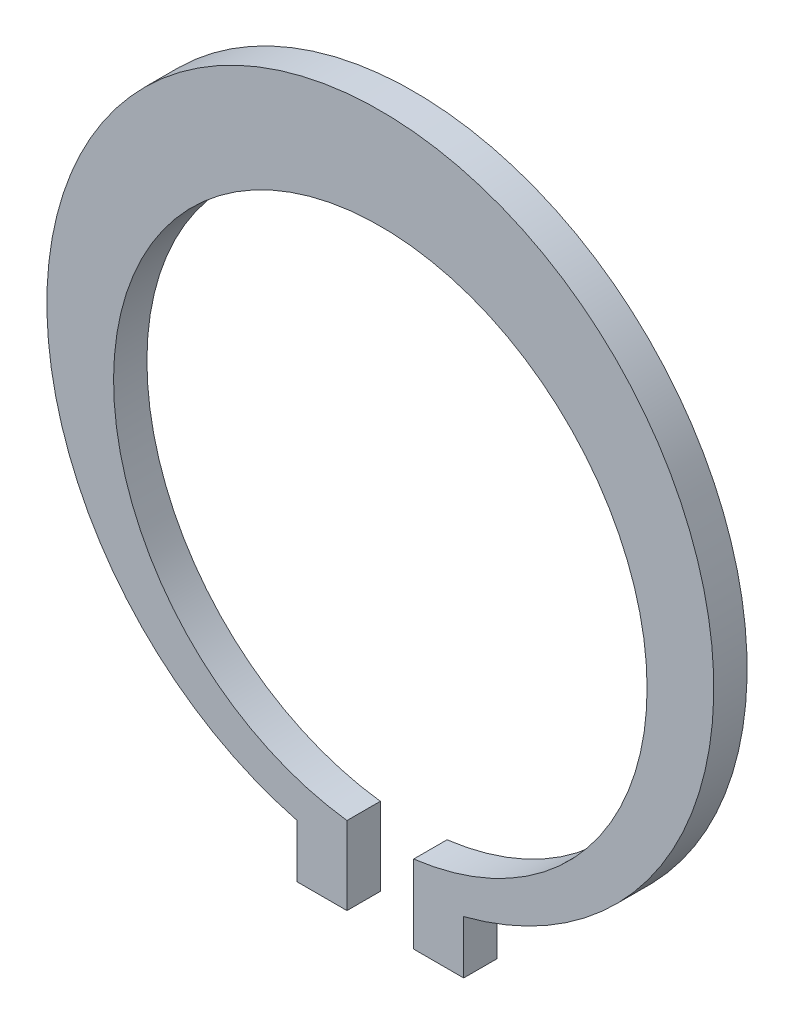
from build123d import *

# Parameters (mm, degrees)
BOSS_EXTRUDE1_DEPTH = 2


with BuildPart() as part:
    # Sketch2 → Boss-Extrude1 (new body)
    with BuildSketch(Plane.XY):
        with BuildLine():
            Line((5, -22.554507866), (5, -19.364916731))
            ThreePointArc((5, -19.364916731), (0, 20), (-5, -19.364916731))
            Line((-5, -19.364916731), (-5, -22.554507866))
            Line((-5, -22.554507866), (-2, -22.554507866))
            Line((-2, -22.554507866), (-2, -17.874507866))
            ThreePointArc((-2, -17.874507866), (0, 14), (2, -17.874507866))
            Line((2, -17.874507866), (2, -22.554507866))
            Line((2, -22.554507866), (5, -22.554507866))
        make_face()
    extrude(amount=BOSS_EXTRUDE1_DEPTH)


solid = part.part
